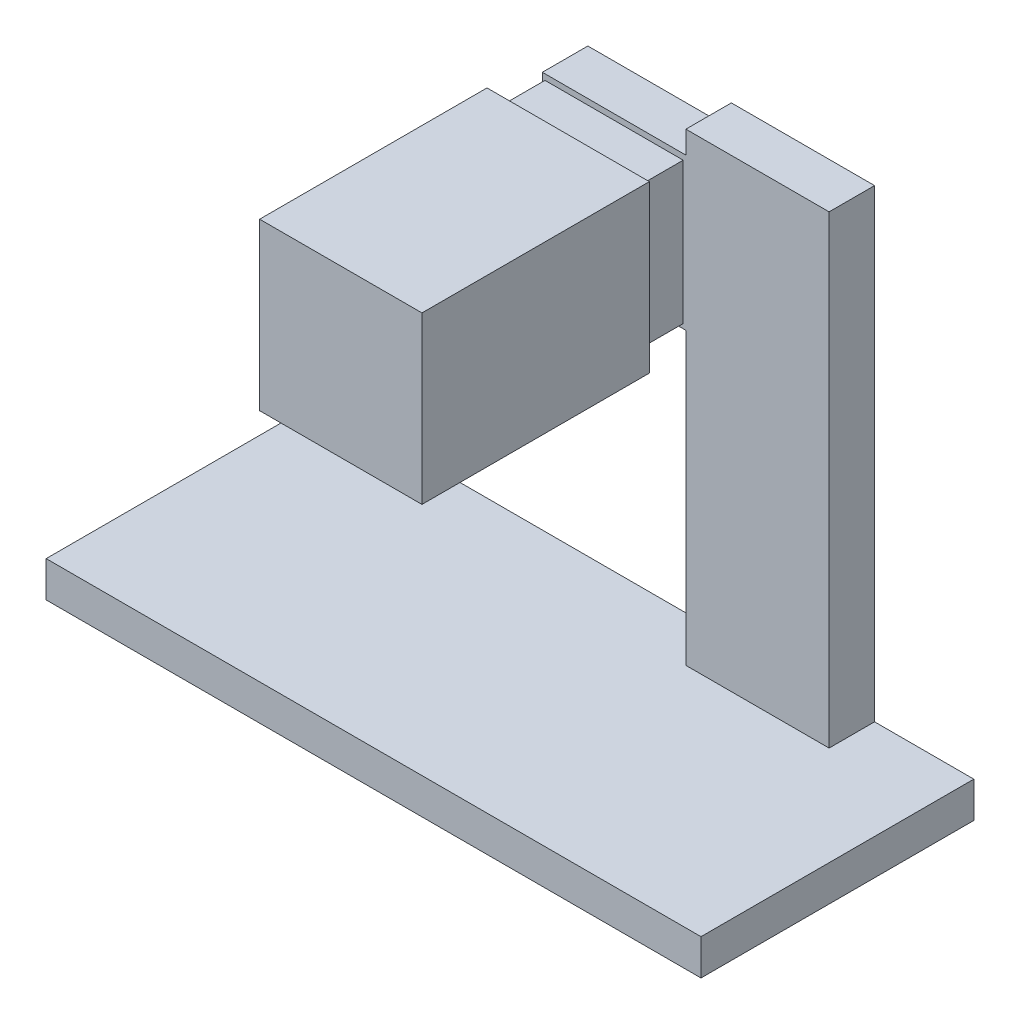
from build123d import *

# Parameters (mm, degrees)
SKETCH1_W           = 182.88
SKETCH1_H           = 76.2
BOSS_EXTRUDE1_DEPTH = 10
SKETCH2_W           = 40
SKETCH2_H           = 12.7
BOSS_EXTRUDE2_DEPTH = 129.7
SKETCH3_W           = 80.079962719
SKETCH3_H           = 42.379632712
BOSS_EXTRUDE3_DEPTH = 12.7
SKETCH4_W           = 38.600527556
SKETCH4_H           = 39.516860555
BOSS_EXTRUDE4_DEPTH = 12.7
SKETCH6_W           = 45.336351273
SKETCH6_H           = 46.321924127
BOSS_EXTRUDE5_DEPTH = 63.5
SKETCH7_R           = 6.35
BOSS_EXTRUDE6_DEPTH = 99.06


with BuildPart() as part:
    # Sketch1 → Boss-Extrude1 (new body)
    with BuildSketch(Plane(origin=(0, 0, 0), x_dir=(1, 0, 0), z_dir=(0, 1, 0))):
        with Locations((91.44, 38.1)):
            Rectangle(SKETCH1_W, SKETCH1_H)
    extrude(amount=BOSS_EXTRUDE1_DEPTH)

    # Sketch2 → Boss-Extrude2 (add)
    with BuildSketch(Plane(origin=(0, 10, 0), x_dir=(1, 0, 0), z_dir=(0, 1, 0))):
        with Locations((135.159453347, 69.85)):
            Rectangle(SKETCH2_W, SKETCH2_H)
    extrude(amount=BOSS_EXTRUDE2_DEPTH)

    # Sketch3 → Boss-Extrude3 (add)
    with BuildSketch(Plane(origin=(0, 0, -76.2), x_dir=(-1, 0, 0), z_dir=(0, 0, -1))):
        with Locations((-115.119471988, 112.229632712)):
            Rectangle(SKETCH3_W, SKETCH3_H)
    extrude(amount=-BOSS_EXTRUDE3_DEPTH)

    # Sketch4 → Boss-Extrude4 (add)
    with BuildSketch(Plane.XY.offset(-63.5)):
        with Locations((95.110147759, 112.061245717)):
            Rectangle(SKETCH4_W, SKETCH4_H)
    extrude(amount=BOSS_EXTRUDE4_DEPTH)

    # Sketch6 → Boss-Extrude5 (add)
    with BuildSketch(Plane.XY.offset(-50.8)):
        with Locations((94.988062274, 111.441174429)):
            Rectangle(SKETCH6_W, SKETCH6_H)
    extrude(amount=BOSS_EXTRUDE5_DEPTH)

    # Sketch7 → Boss-Extrude6 (add)
    with BuildSketch(Plane.XY.offset(12.7)):
        with Locations((94.988062274, 111.441174429)):
            Circle(SKETCH7_R)
    extrude(amount=-BOSS_EXTRUDE6_DEPTH)


solid = part.part
